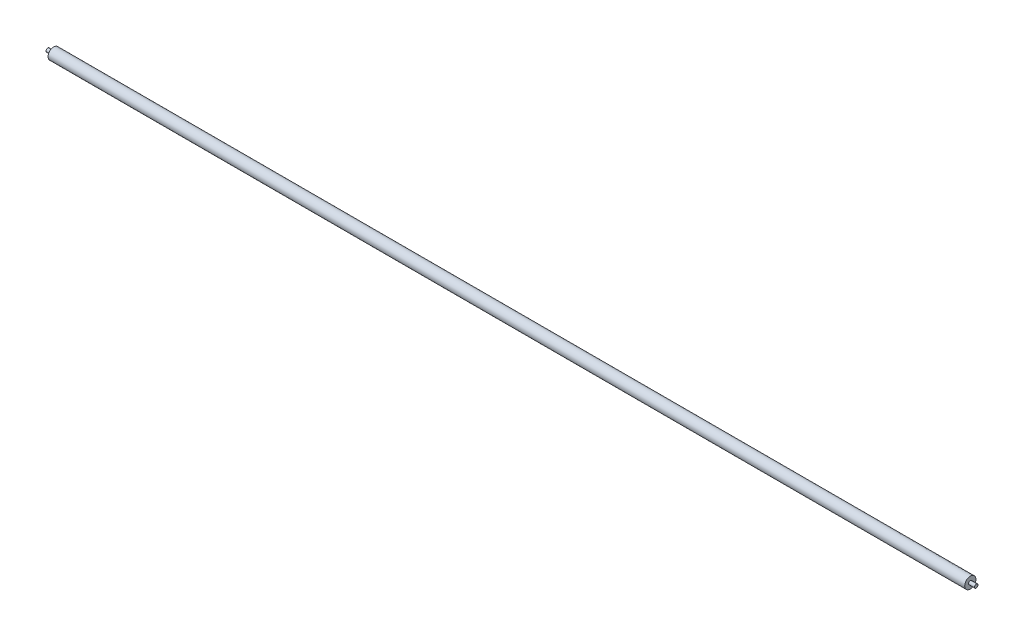
from build123d import *

# Parameters (mm, degrees)
SKETCH1_R           = 9.5
BOSS_EXTRUDE1_DEPTH = 1554
SKETCH2_R           = 3
BOSS_EXTRUDE2_DEPTH = 10
SKETCH3_R           = 3
BOSS_EXTRUDE3_DEPTH = 10


with BuildPart() as part:
    # Sketch1 → Boss-Extrude1 (new body)
    with BuildSketch(Plane(origin=(0, 0, 0), x_dir=(0, 0, -1), z_dir=(1, 0, 0))):
        Circle(SKETCH1_R)
    extrude(amount=BOSS_EXTRUDE1_DEPTH)

    # Sketch2 → Boss-Extrude2 (add)
    with BuildSketch(Plane.ZY):
        Circle(SKETCH2_R)
    extrude(amount=BOSS_EXTRUDE2_DEPTH)

    # Sketch3 → Boss-Extrude3 (add)
    with BuildSketch(Plane(origin=(1554, 0, 0), x_dir=(0, 0, -1), z_dir=(1, 0, 0))):
        Circle(SKETCH3_R)
    extrude(amount=BOSS_EXTRUDE3_DEPTH)


solid = part.part
